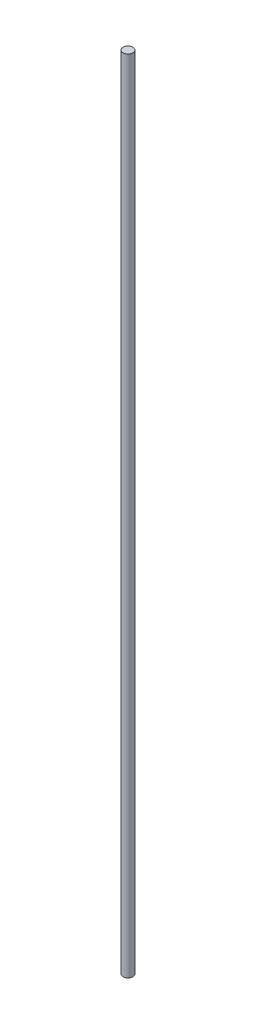
from build123d import *

# Parameters (mm, degrees)
SKETCH1_R           = 4
BOSS_EXTRUDE1_DEPTH = 650


with BuildPart() as part:
    # Sketch1 → Boss-Extrude1 (new body)
    with BuildSketch(Plane(origin=(0, 0, 0), x_dir=(1, 0, 0), z_dir=(0, 1, 0))):
        Circle(SKETCH1_R)
    extrude(amount=BOSS_EXTRUDE1_DEPTH)


solid = part.part
